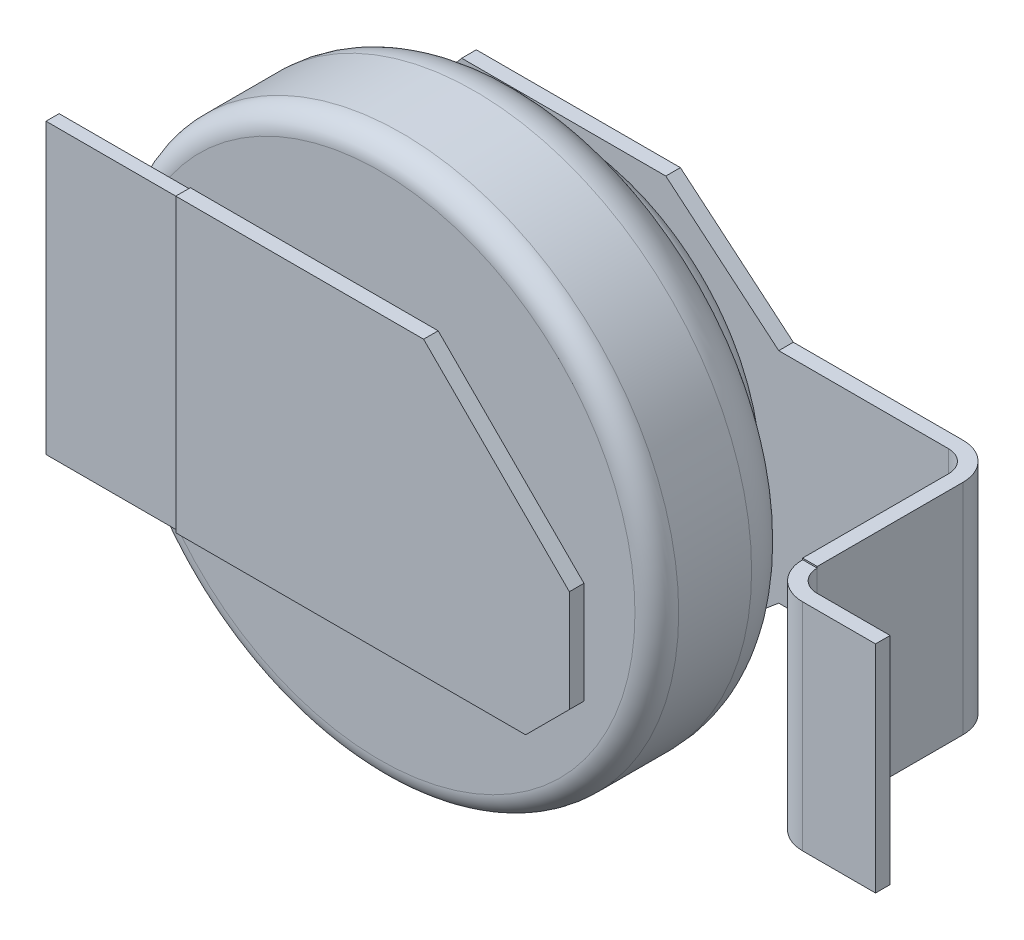
from build123d import *

# Parameters (mm, degrees)
BOSS_EXTRUDE1_DEPTH = 0.1
SKETCH4_W           = 0.9
SKETCH4_H           = 2
CUT_EXTRUDE1_DEPTH  = 0.01
SKETCH5_W           = 0.9
SKETCH5_H           = 0.09
CUT_EXTRUDE2_DEPTH  = 0.01
SKETCH6_W           = 0.9
SKETCH6_H           = 0.09
CUT_EXTRUDE3_DEPTH  = 0.01
BOSS_EXTRUDE2_DEPTH = 0.1
SKETCH9_W           = 0.1
SKETCH9_H           = 1.5
SKETCH10_W          = 0.8
SKETCH10_H          = 0.25
CUT_EXTRUDE4_DEPTH  = 0.01
SKETCH11_W          = 0.8
SKETCH11_H          = 0.25
CUT_EXTRUDE5_DEPTH  = 0.01


with BuildPart() as part:
    # Sketch1 → Revolve1 (revolve)
    with BuildSketch(Plane(origin=(0, 0, 0), x_dir=(1, 0, 0), z_dir=(0, 1, 0))):
        with BuildLine():
            Line((0, 0), (0, 1.3))
            Line((0, 1.3), (-1.25, 1.3))
            ThreePointArc((-1.25, 1.3), (-1.356066017, 1.256066017), (-1.4, 1.15))
            Line((-1.4, 1.15), (-1.4, 1.1))
            Line((-1.4, 1.1), (-1.42, 1.1))
            ThreePointArc((-1.42, 1.1), (-1.476568542, 1.076568542), (-1.5, 1.02))
            Line((-1.5, 1.02), (-1.5, 1))
            Line((-1.5, 1), (-1.55, 1))
            ThreePointArc((-1.55, 1), (-1.797487373, 0.897487373), (-1.9, 0.65))
            Line((-1.9, 0.65), (-1.9, 0.15))
            ThreePointArc((-1.9, 0.15), (-1.856066017, 0.043933983), (-1.75, 0))
            Line((-1.75, 0), (0, 0))
        make_face()
    revolve(axis=Axis((0, 0, 0), (0, 0, -1)))

    # Sketch2 → Boss-Extrude1 (add)
    with BuildSketch(Plane.XY):
        Polygon((-2.2, 1), (-2.2, -1), (1.1, -1), (1.4, -0.7), (1.4, 0), (0.4, 1), align=None)
    extrude(amount=BOSS_EXTRUDE1_DEPTH)

    # Sketch4 → Cut-Extrude1 (cut)
    with BuildSketch(Plane.XY.offset(0.1)):
        with Locations((-1.75, 0)):
            Rectangle(SKETCH4_W, SKETCH4_H)
    extrude(amount=-CUT_EXTRUDE1_DEPTH, mode=Mode.SUBTRACT)

    # Sketch5 → Cut-Extrude2 (cut)
    with BuildSketch(Plane(origin=(0, 1, 0), x_dir=(1, 0, 0), z_dir=(0, 1, 0))):
        with Locations((-1.75, -0.045)):
            Rectangle(SKETCH5_W, SKETCH5_H)
    extrude(amount=-CUT_EXTRUDE2_DEPTH, mode=Mode.SUBTRACT)

    # Sketch6 → Cut-Extrude3 (cut)
    with BuildSketch(Plane.XZ.offset(1)):
        with Locations((-1.75, 0.045)):
            Rectangle(SKETCH6_W, SKETCH6_H)
    extrude(amount=-CUT_EXTRUDE3_DEPTH, mode=Mode.SUBTRACT)

    # Sketch7 → Boss-Extrude2 (add)
    with BuildSketch(Plane(origin=(0, 0, -1.3), x_dir=(-1, 0, 0), z_dir=(0, 0, -1))):
        Polygon((1.2, 0.85), (1.2, -0.85), (0.738495203, -1.4), (-0.661504797, -1.4), (-1.436144632, -0.75), (-2.5, -0.75), (-2.5, 0.75), (-1.436144632, 0.75), (-0.661504797, 1.4), (0.738495203, 1.4), align=None)
    extrude(amount=BOSS_EXTRUDE2_DEPTH)

    # Sweep1: sweep along a path in Sketch8
    with BuildLine(Plane(origin=(0, 0, 0), x_dir=(1, 0, 0), z_dir=(0, 1, 0))) as sweep1_path:
        Line((2.5, 1.35), (2.599997807, 1.35))
        ThreePointArc((2.599997807, 1.35), (2.741419163, 1.291421356), (2.799997807, 1.15))
        Line((2.799997807, 1.15), (2.799997807, 0.15))
        ThreePointArc((2.799997807, 0.15), (2.858576451, 0.008578644), (2.999997807, -0.05))
        Line((2.999997807, -0.05), (3.499997807, -0.05))
    # Sketch9 → Sweep1 (sweep)
    with BuildSketch(Plane(origin=(2.5, 0, 0), x_dir=(0, 0, -1), z_dir=(1, 0, 0))):
        with Locations((1.35, 0)):
            Rectangle(SKETCH9_W, SKETCH9_H)
    sweep(path=sweep1_path.line)

    # Sketch10 → Cut-Extrude4 (cut)
    with BuildSketch(Plane(origin=(0, 0.75, 0), x_dir=(1, 0, 0), z_dir=(0, 1, 0))):
        with Locations((3.099997807, 0.025)):
            Rectangle(SKETCH10_W, SKETCH10_H)
    extrude(amount=-CUT_EXTRUDE4_DEPTH, mode=Mode.SUBTRACT)

    # Sketch11 → Cut-Extrude5 (cut)
    with BuildSketch(Plane.XZ.offset(0.75)):
        with Locations((3.099997807, -0.025)):
            Rectangle(SKETCH11_W, SKETCH11_H)
    extrude(amount=-CUT_EXTRUDE5_DEPTH, mode=Mode.SUBTRACT)


solid = part.part
